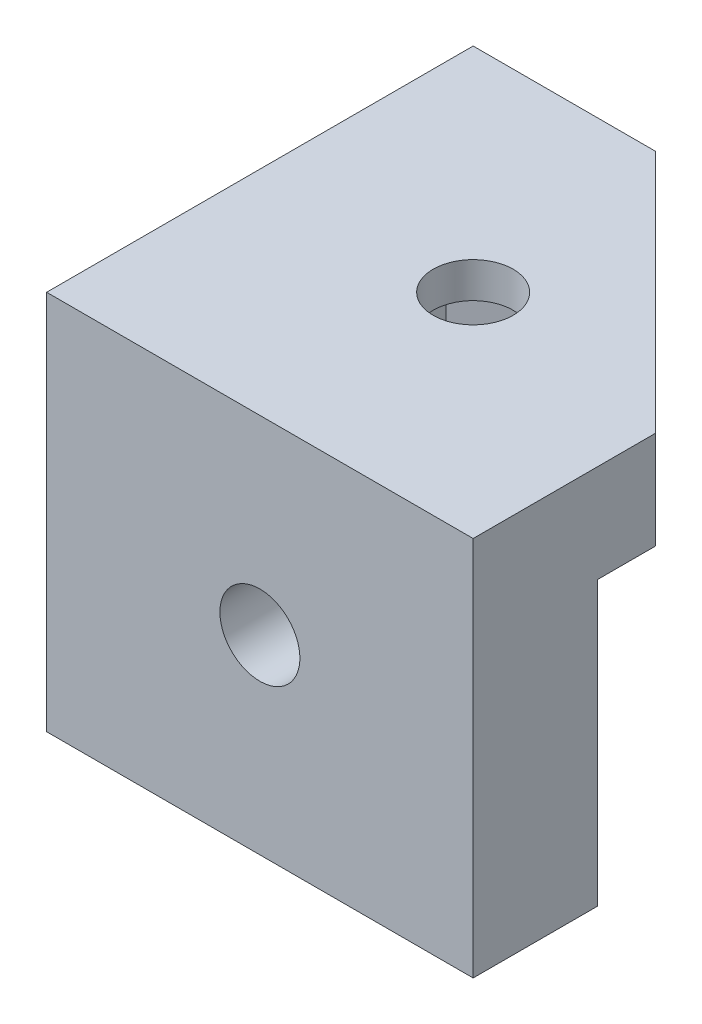
from build123d import *

# Parameters (mm, degrees)
SKETCH1_W                    = 38.1
SKETCH1_H                    = 38.1
MAIN_BODY_DEPTH              = 34
SKETCH3_R                    = 3.571875
F_9_32_RIGHT_RAIL_DEPTH      = 1
F_9_32_RIGHT_RAIL_DEPTH_BACK = 5.55625
SKETCH4_R                    = 3.571875
F_9_32_LEFT_RAIL_DEPTH       = 5.55625
SKETCH8_R                    = 3.571875
F_9_32_TOPPER_DEPTH          = 1
F_9_32_TOPPER_DEPTH_BACK     = 10
HEX_START                    = -5.55625
HEX_HOLE_RIGHT_DEPTH         = 32.54375
HEX_HOLE_LEFT_DEPTH          = 32.54375
INNER_START                  = -17.4625
SKETCH13_W                   = 26.9875
SKETCH13_H                   = 26.9875
INNER_CAVITY_DEPTH           = 8.73125
INNER_CAVITY_DEPTH_BACK      = 22.754687
HEX_START_2                  = -17
HEX_HOLE_TOP_DEPTH           = 13.825
TOP_CORNER_REACH             = 36


with BuildPart() as part:
    # Sketch1 → Main Body (new body)
    with BuildSketch(Plane(origin=(0, 0, 0), x_dir=(1, 0, 0), z_dir=(0, 1, 0))):
        with Locations((19.05, 19.05)):
            Rectangle(SKETCH1_W, SKETCH1_H)
    extrude(amount=MAIN_BODY_DEPTH)

    # Sketch3 → 9/32 Right Rail (cut, two sides)
    with BuildSketch(Plane.XY) as f_9_32_right_rail_sk:
        with Locations((19.05, 17)):
            Circle(SKETCH3_R)
    extrude(amount=F_9_32_RIGHT_RAIL_DEPTH, mode=Mode.SUBTRACT)
    extrude(f_9_32_right_rail_sk.sketch, amount=-F_9_32_RIGHT_RAIL_DEPTH_BACK, mode=Mode.SUBTRACT)

    # Sketch4 → 9/32 Left Rail (cut)
    with BuildSketch(Plane.ZY):
        with Locations((-19.05, 17)):
            Circle(SKETCH4_R)
    extrude(amount=-F_9_32_LEFT_RAIL_DEPTH, mode=Mode.SUBTRACT)

    # Sketch8 → 9/32 Topper (cut, two sides)
    with BuildSketch(Plane(origin=(0, 34, 0), x_dir=(1, 0, 0), z_dir=(0, 1, 0))) as f_9_32_topper_sk:
        with Locations((19.05, 19.05)):
            Circle(SKETCH8_R)
    extrude(amount=F_9_32_TOPPER_DEPTH, mode=Mode.SUBTRACT)
    extrude(f_9_32_topper_sk.sketch, amount=-F_9_32_TOPPER_DEPTH_BACK, mode=Mode.SUBTRACT)

    # Sketch9 → Hex Hole Right (cut)
    with BuildSketch(Plane.ZY.offset(HEX_START)):
        Polygon((-22.372470377, 22.7546875), (-25.694940754, 17), (-22.372470377, 11.2453125), (-15.727529623, 11.2453125), (-12.405059246, 17), (-15.727529623, 22.7546875), align=None)
    extrude(amount=-HEX_HOLE_RIGHT_DEPTH, mode=Mode.SUBTRACT)

    # Sketch10 → Hex Hole Left (cut)
    with BuildSketch(Plane.XY.offset(HEX_START)):
        Polygon((15.727529623, 22.7546875), (12.405059246, 17), (15.727529623, 11.2453125), (22.372470377, 11.2453125), (25.694940754, 17), (22.372470377, 22.7546875), align=None)
    extrude(amount=-HEX_HOLE_LEFT_DEPTH, mode=Mode.SUBTRACT)

    # Sketch13 → Inner Cavity (cut, two sides)
    with BuildSketch(Plane(origin=(0, 34, 0), x_dir=(1, 0, 0), z_dir=(0, 1, 0)).offset(INNER_START)) as inner_cavity_sk:
        with Locations((24.60625, 24.60625)):
            Rectangle(SKETCH13_W, SKETCH13_H)
    extrude(amount=INNER_CAVITY_DEPTH, mode=Mode.SUBTRACT)
    extrude(inner_cavity_sk.sketch, amount=-INNER_CAVITY_DEPTH_BACK, mode=Mode.SUBTRACT)

    # Sketch14 → Hex Hole Top (cut)
    with BuildSketch(Plane(origin=(0, 34, 0), x_dir=(1, 0, 0), z_dir=(0, 1, 0)).offset(HEX_START_2)):
        Polygon((24.8046875, 22.372470377), (19.05, 25.694940754), (13.2953125, 22.372470377), (13.2953125, 15.727529623), (19.05, 12.405059246), (24.8046875, 15.727529623), align=None)
    extrude(amount=HEX_HOLE_TOP_DEPTH, mode=Mode.SUBTRACT)

    # Sketch16 → Top Corner (cut, up to next)
    with BuildSketch(Plane(origin=(0, 34, 0), x_dir=(1, 0, 0), z_dir=(0, 1, 0)), mode=Mode.PRIVATE) as top_corner_sk1:
        Polygon((38.1, 38.1), (16.276714219, 38.1), (38.1, 16.276714219), align=None)
    top_corner_tool1 = extrude(top_corner_sk1.sketch, amount=-TOP_CORNER_REACH, mode=Mode.PRIVATE) & part.part
    add(top_corner_tool1.solids().sort_by_distance((30.825571, 34, -30.825571))[0], mode=Mode.SUBTRACT)


solid = part.part
